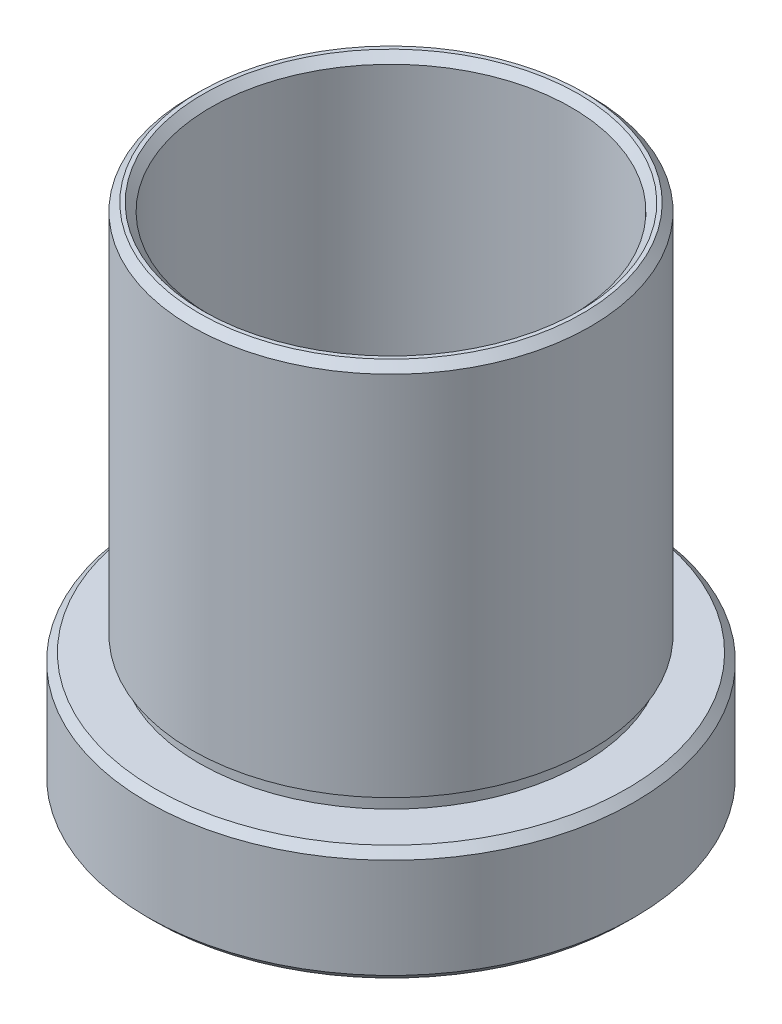
from build123d import *


with BuildPart() as part:
    # 草图1 → 旋转2 (revolve)
    with BuildSketch(Plane.XY, mode=Mode.PRIVATE) as revolve_2_sk:
        Polygon((12.25, 27.042854175), (12.5, 27.042854175), (13, 26.542854175), (13, 2.642854175), (12.5, 2.642854175), (12.5, 1.642854175), (15.375, 1.642854175), (15.875, 1.142854175), (15.875, -5.357145825), (15.375, -5.857145825), (14.75, -5.857145825), (14.25, -5.357145825), (14.25, -1.357145825), (14.35, -1.357145825), (14.35, -0.357145825), (11.75, -0.357145825), (11.75, 26.542854175), align=None)
    revolve(revolve_2_sk.sketch.rotate(Axis((0, 44.598597745, 0), (0, -1, 0)), 90), axis=Axis((0, 44.598597745, 0), (0, -1, 0)))  # turned: the seam where the file's is


solid = part.part
